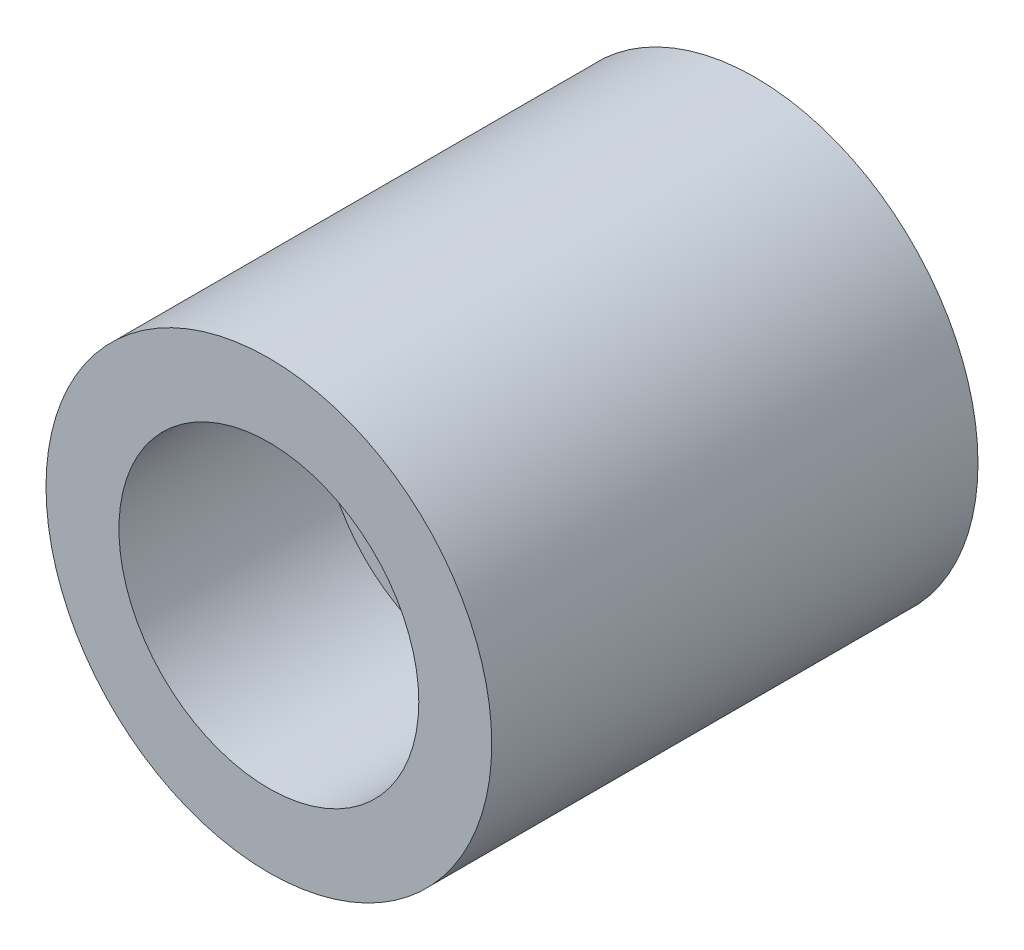
from build123d import *

# Parameters (mm, degrees)
SKICA1_R                 = 2.75
P_IDAT_VYSUNUT_M1_DEPTH  = 6
SKICA2_R                 = 1.85
ODEBRAT_VYSUNUT_M1_DEPTH = 2.5


with BuildPart() as part:
    # Skica1 → Přidat vysunutím1 (new body)
    with BuildSketch(Plane.XY):
        Circle(SKICA1_R)
    extrude(amount=P_IDAT_VYSUNUT_M1_DEPTH)

    # Skica2 → Odebrat vysunutím1 (cut)
    with BuildSketch(Plane.XY.offset(6)):
        Circle(SKICA2_R)
    extrude(amount=-ODEBRAT_VYSUNUT_M1_DEPTH, mode=Mode.SUBTRACT)


solid = part.part
